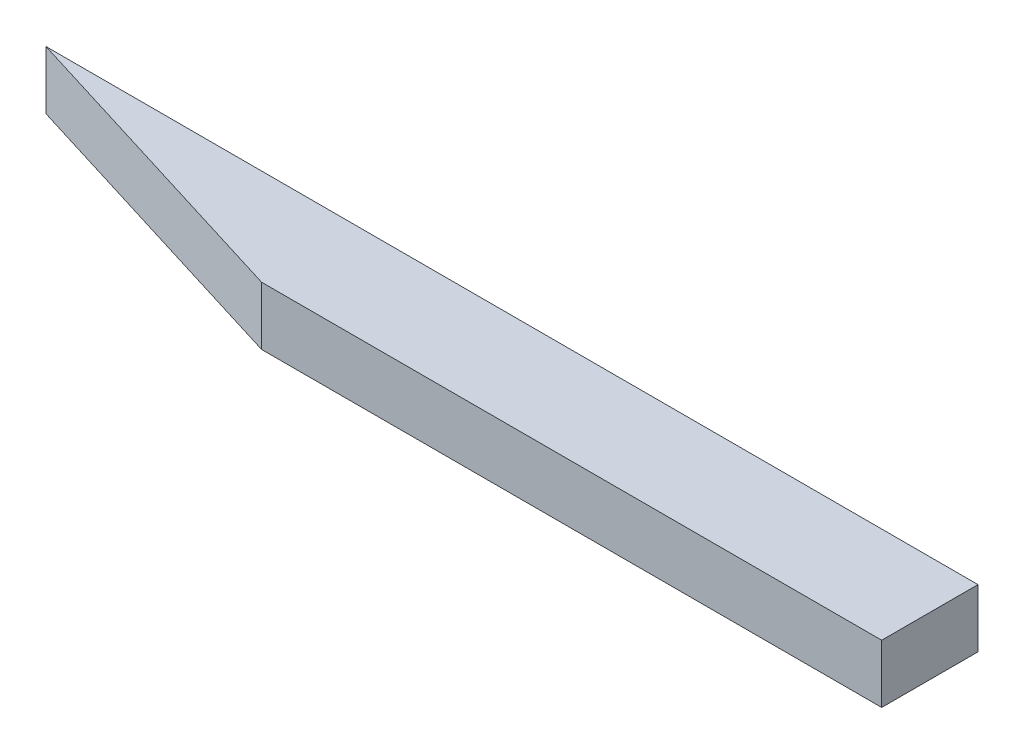
from build123d import *

# Parameters (mm, degrees)
BOSS_EXTRUDE1_DEPTH = 6.35


with BuildPart() as part:
    # Sketch1 → Boss-Extrude1 (new body, symmetric)
    with BuildSketch(Plane(origin=(0, 0, 0), x_dir=(1, 0, 0), z_dir=(0, 1, 0))):
        Polygon((0, 0), (203.2, 0), (203.2, -21), (68, -21), align=None)
    extrude(amount=BOSS_EXTRUDE1_DEPTH, both=True)


solid = part.part
